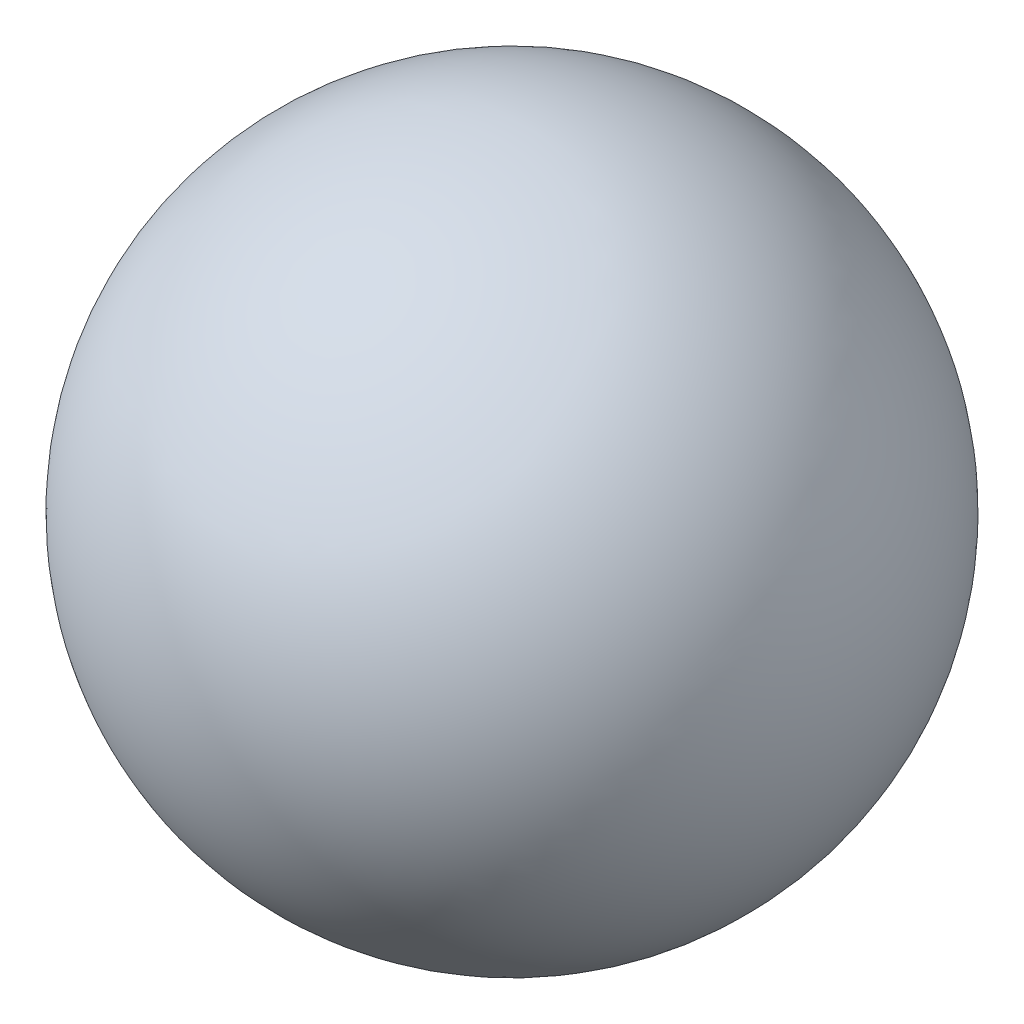
from build123d import *


with BuildPart() as part:
    # Sketch2 → Revolve11 (revolve)
    with BuildSketch(Plane(origin=(0, 0, 0), x_dir=(1, 0, 0), z_dir=(0, 1, 0))):
        with BuildLine():
            Line((0, 3.175), (0, -1.5875))
            ThreePointArc((0, -1.5875), (2.38125, 0.79375), (0, 3.175))
        make_face()
    revolve(axis=Axis((0, 0, -3.175), (0, 0, 1)))


solid = part.part
